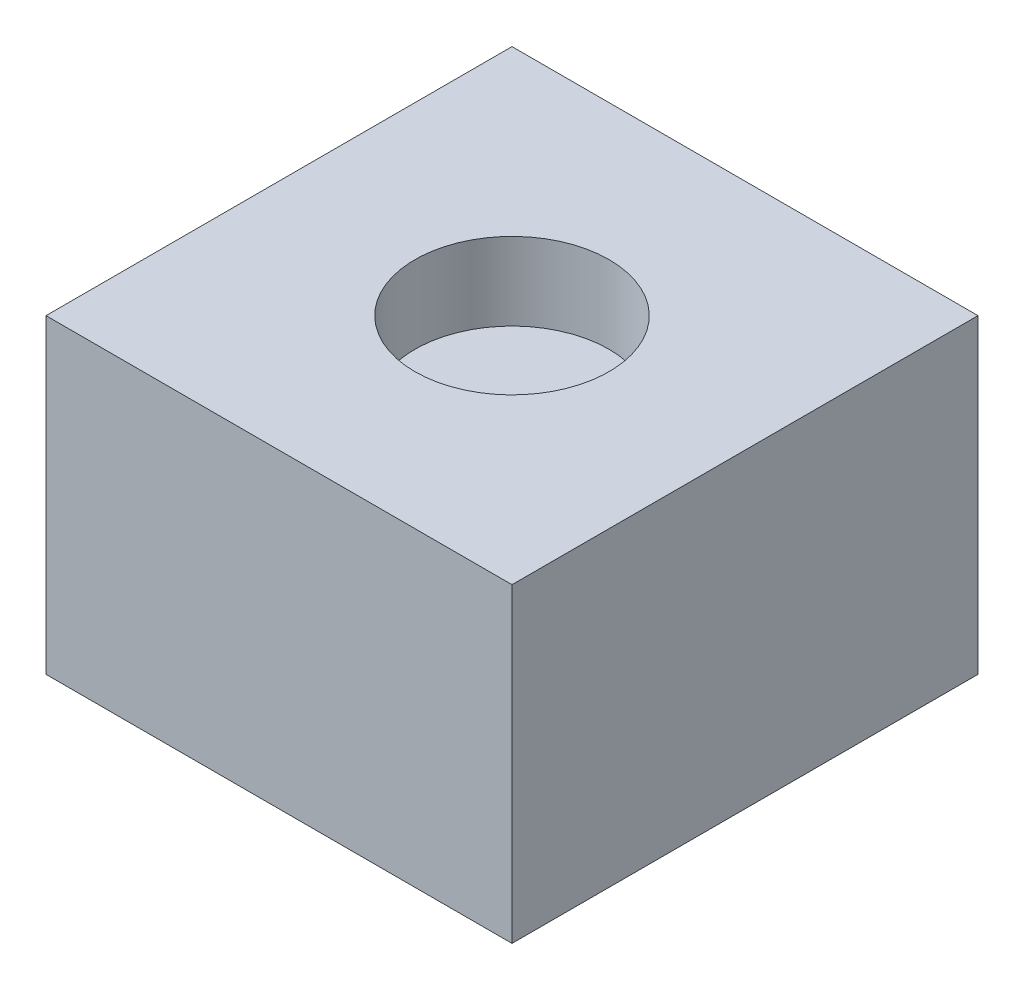
from build123d import *

# Parameters (mm, degrees)
SKETCH1_W           = 12
SKETCH1_H           = 12
BOSS_EXTRUDE1_DEPTH = 8
SKETCH2_R           = 2.5
CUT_EXTRUDE1_DEPTH  = 2
SKETCH3_R           = 1
CUT_EXTRUDE2_DEPTH  = 2
FILLET1_R           = 1


with BuildPart() as part:
    # Sketch1 → Boss-Extrude1 (new body)
    with BuildSketch(Plane(origin=(0, 0, 0), x_dir=(1, 0, 0), z_dir=(0, 1, 0))):
        Rectangle(SKETCH1_W, SKETCH1_H)
    extrude(amount=BOSS_EXTRUDE1_DEPTH)

    # Sketch2 → Cut-Extrude1 (cut)
    with BuildSketch(Plane(origin=(0, 8, 0), x_dir=(1, 0, 0), z_dir=(0, 1, 0))):
        Circle(SKETCH2_R)
    extrude(amount=-CUT_EXTRUDE1_DEPTH, mode=Mode.SUBTRACT)

    # Sketch3 → Cut-Extrude2 (cut)
    with BuildSketch(Plane.XZ):
        Circle(SKETCH3_R)
    extrude(amount=-CUT_EXTRUDE2_DEPTH, mode=Mode.SUBTRACT)

    # Fillet1
    fillet1_edges = [part.edges().sort_by_distance(p)[0] for p in [
        (-1, 2, 0),
    ]]
    fillet(fillet1_edges, radius=FILLET1_R)


solid = part.part
